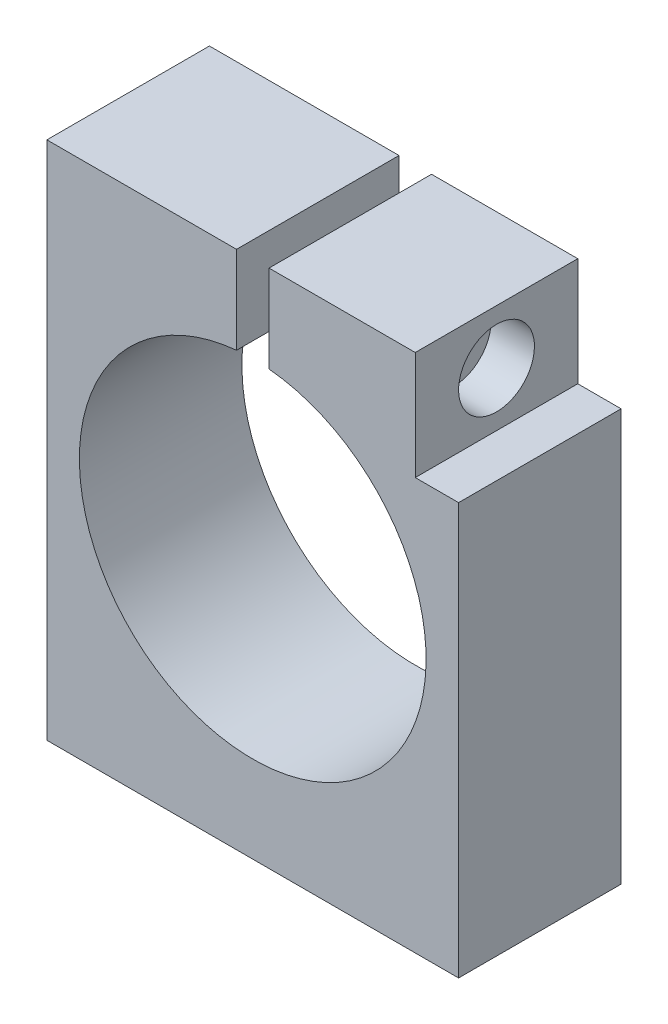
from build123d import *

# Parameters (mm, degrees)
BOSS_EXTRU_1_DEPTH      = 15
ESQUISSE2_R             = 3.5
ENL_V_MAT_EXTRU_1_DEPTH = 4
ESQUISSE5_R             = 1.75
ENL_V_MAT_EXTRU_2_DEPTH = 20


with BuildPart() as part:
    # Esquisse1 → Boss.-Extru.1 (new body)
    with BuildSketch(Plane.XY):
        with BuildLine():
            Line((8.142533049, 9), (8.142533049, 19))
            Line((8.142533049, 19), (-5.354330929, 19))
            Line((-5.354330929, 19), (-5.354330929, 10.929236708))
            ThreePointArc((-5.354330929, 10.929236708), (4.975752737, 5.769164862), (9.142533049, -5))
            ThreePointArc((9.142533049, -5), (-17.628961192, -16.83109935), (-8.354330929, 10.929827313))
            Line((-8.354330929, 10.929827313), (-8.354330929, 19))
            Line((-8.354330929, 19), (-25.857466951, 19))
            Line((-25.857466951, 19), (-25.857466951, -29))
            Line((-25.857466951, -29), (12.142533049, -29))
            Line((12.142533049, -29), (12.142533049, 9))
            Line((12.142533049, 9), (8.142533049, 9))
        make_face()
    extrude(amount=BOSS_EXTRU_1_DEPTH)

    # Esquisse2 → Enlèv. mat.-Extru.1 (cut)
    with BuildSketch(Plane(origin=(8.142533049, 0, 0), x_dir=(0, 0, -1), z_dir=(1, 0, 0))):
        with Locations((-7.5, 14)):
            Circle(ESQUISSE2_R)
    extrude(amount=-ENL_V_MAT_EXTRU_1_DEPTH, mode=Mode.SUBTRACT)

    # Esquisse5 → Enlèv. mat.-Extru.2 (cut)
    with BuildSketch(Plane(origin=(4.142533049, 0, 0), x_dir=(0, 0, -1), z_dir=(1, 0, 0))):
        with Locations((-7.5, 14)):
            Circle(ESQUISSE5_R)
    extrude(amount=-ENL_V_MAT_EXTRU_2_DEPTH, mode=Mode.SUBTRACT)


solid = part.part
